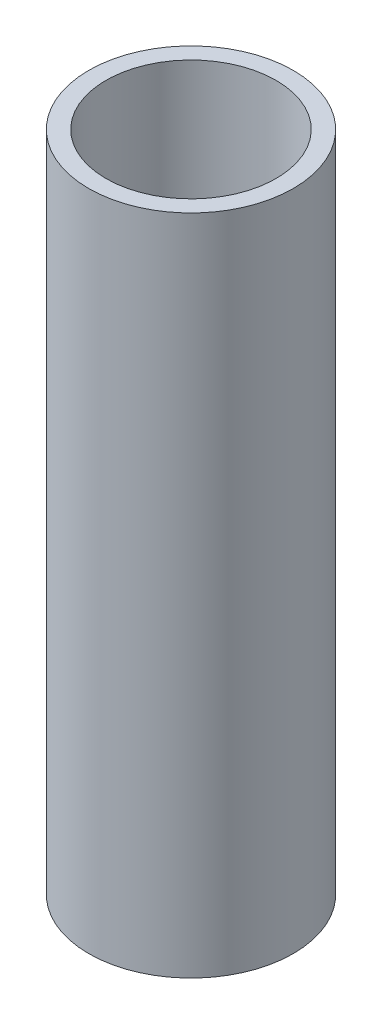
from build123d import *

# Parameters (mm, degrees)
SKETCH1_R           = 21.082
SKETCH1_R_2         = 17.526
BOSS_EXTRUDE1_DEPTH = 136.525


with BuildPart() as part:
    # Sketch1 → Boss-Extrude1 (new body)
    with BuildSketch(Plane(origin=(0, 0, 0), x_dir=(1, 0, 0), z_dir=(0, 1, 0))):
        Circle(SKETCH1_R)
        Circle(SKETCH1_R_2, mode=Mode.SUBTRACT)
    extrude(amount=BOSS_EXTRUDE1_DEPTH)


solid = part.part
